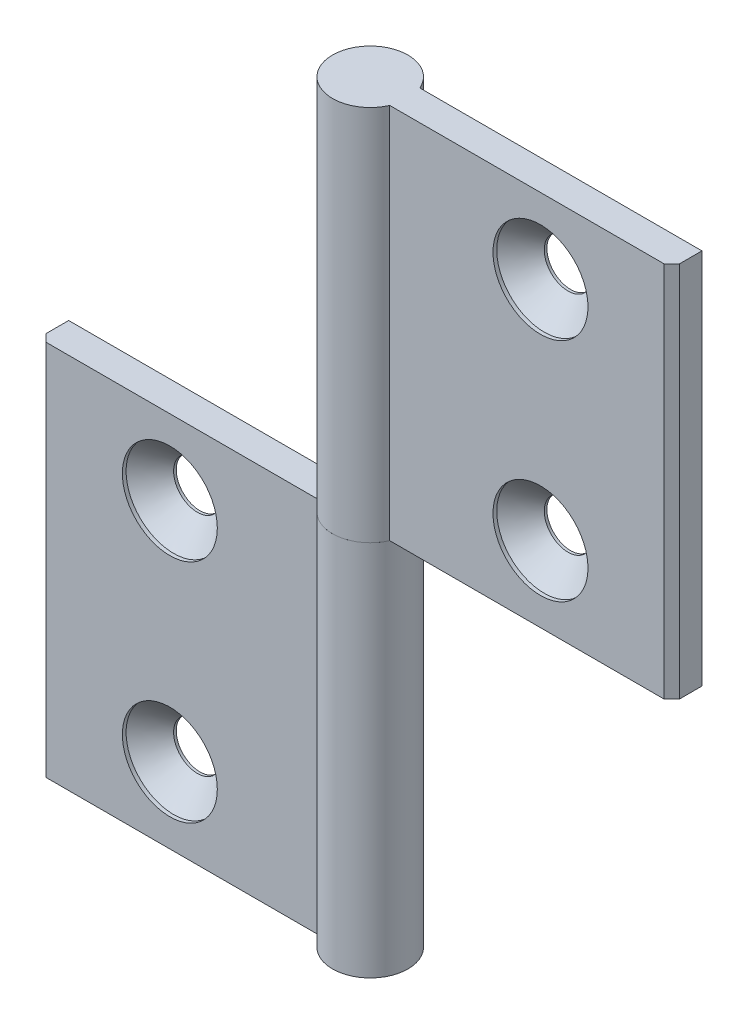
from build123d import *

# Parameters (mm, degrees)
EXTRUDE_1_DEPTH            = 25
HOLE_WIZARD_M61_AT_2_COUNT = 2
HOLE_WIZARD_M61_AT_2_PITCH = 30
PATTERN_CIRCULAR_1_COUNT   = 2


with BuildPart() as part:
    # Эскиз1 → Бобышка-Вытянуть1 (new body, symmetric)
    with BuildSketch(Plane(origin=(0, 0, 0), x_dir=(1, 0, 0), z_dir=(0, 1, 0))):
        with BuildLine():
            Line((-4.582575695, 2), (-42, 2))
            Line((-42, 2), (-42, -1))
            Line((-42, -1), (-41, -2))
            Line((-41, -2), (-4.582575695, -2))
            ThreePointArc((-4.582575695, -2), (5, 0), (-4.582575695, 2))
        make_face()
    extrude(amount=EXTRUDE_1_DEPTH, both=True)

    # Эскиз6 → Зенковка для винта с полупотайной головкой M61 (revolve, cut)
    with BuildSketch(Plane(origin=(-24.582575695, 15, 2), x_dir=(0, -1, 0), z_dir=(1, 0, 0))):
        Polygon((0, 0), (0, 7), (3.15, 7), (3.15, 3.65), (6.3, 0.5), (6.3, 0), align=None)
    hole_wizard_m61 = revolve(axis=Axis((-24.582575695, 15, 8.35), (0, 0, -1)), mode=Mode.SUBTRACT)

    # Зенковка для винта с полупотайной головкой M61 at 2: Зенковка для винта с полупотайной головкой M61 ×2
    with Locations(*[(0, -i * HOLE_WIZARD_M61_AT_2_PITCH, 0) for i in range(1, HOLE_WIZARD_M61_AT_2_COUNT)]):
        add(hole_wizard_m61, mode=Mode.SUBTRACT)


with BuildPart() as pattern_circular_1_1:
    # Круговой массив1: pattern copy
    add(part.part.rotate(Axis((0, 25, 0), (0, 0, 1)), 1 * 360 / PATTERN_CIRCULAR_1_COUNT))


solid = Compound([part.part, pattern_circular_1_1.part])
